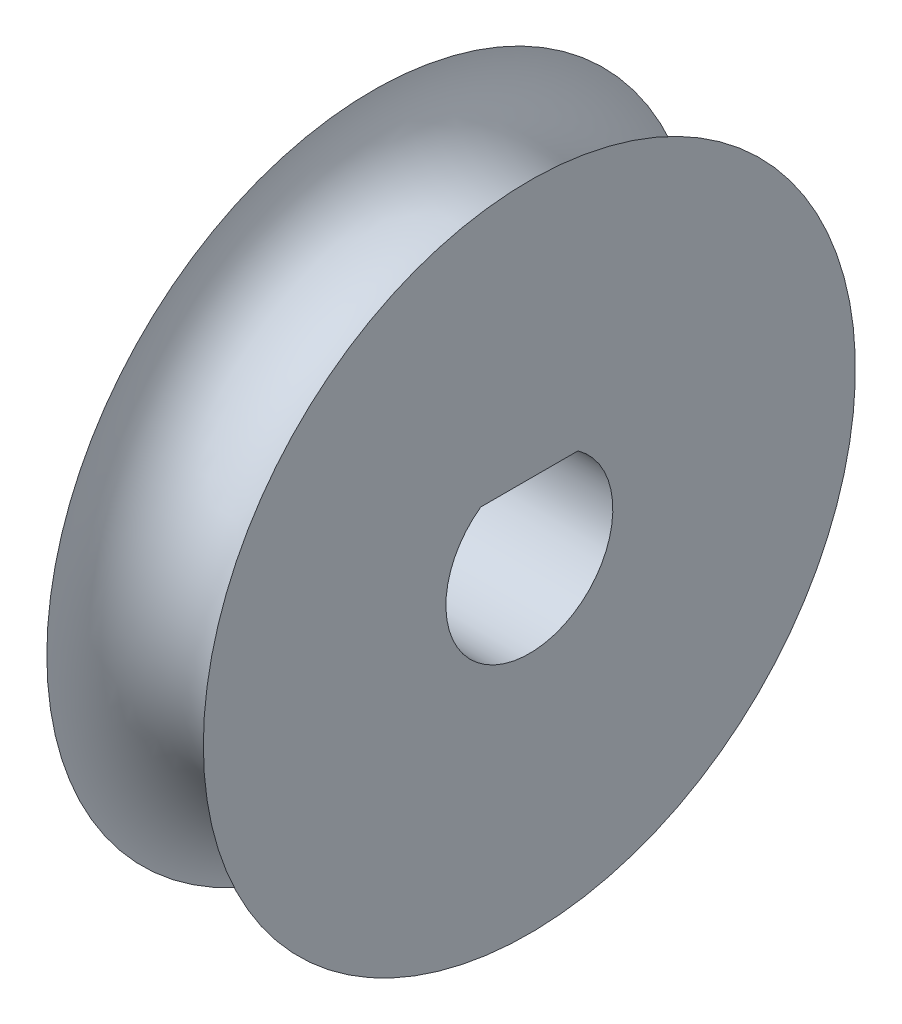
from build123d import *

# Parameters (mm, degrees)
CUT_EXTRUDE1_DEPTH = 8.62


with BuildPart() as part:
    # Sketch1 → Revolve1 (revolve)
    with BuildSketch(Plane.XY):
        with BuildLine():
            Line((-3.81, 15.875), (-3.81, 0))
            Line((-3.81, 0), (3.81, 0))
            Line((3.81, 0), (3.81, 15.875))
            ThreePointArc((3.81, 15.875), (0, 12.065), (-3.81, 15.875))
        make_face()
    revolve(axis=Axis((-3.81, 0, 0), (1, 0, 0)))

    # Sketch2 → Cut-Extrude1 (cut, through all)
    with BuildSketch(Plane(origin=(3.81, 0, 0), x_dir=(0, 0, -1), z_dir=(1, 0, 0))):
        with BuildLine():
            Line((-2.369154279, 3.302), (2.369154279, 3.302))
            ThreePointArc((2.369154279, 3.302), (0, -4.064), (-2.369154279, 3.302))
        make_face()
    extrude(amount=-CUT_EXTRUDE1_DEPTH, mode=Mode.SUBTRACT)


solid = part.part
